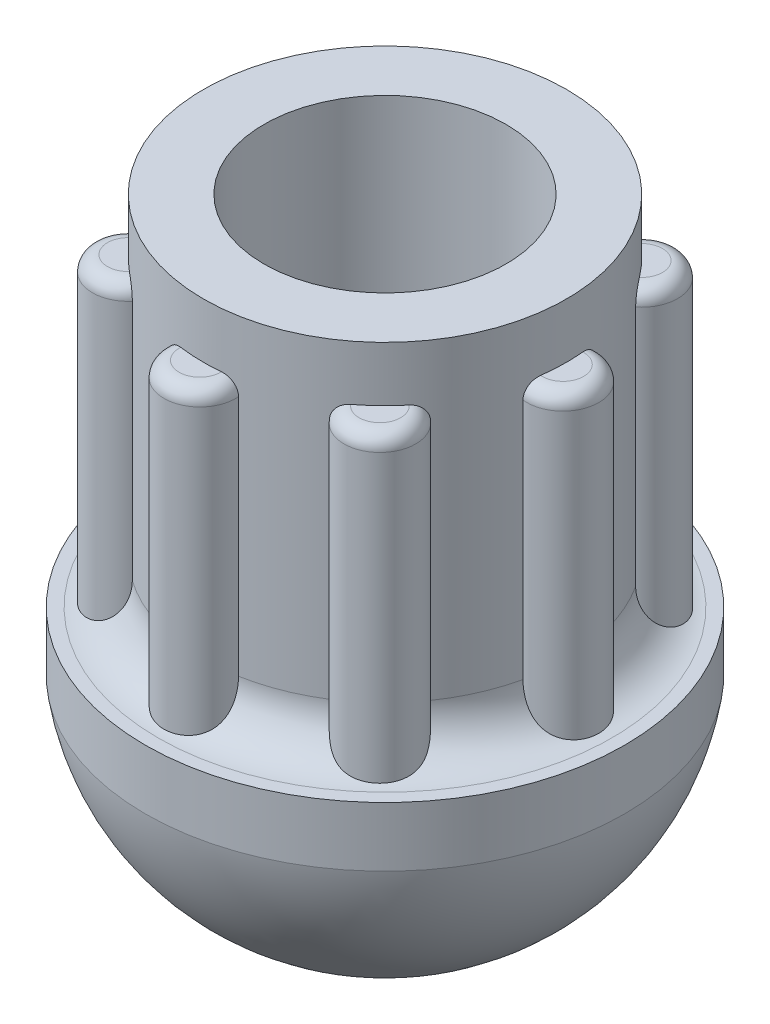
from build123d import *

# Parameters (mm, degrees)
SKETCH2_R           = 1.186722436
BOSS_EXTRUDE1_DEPTH = 10
FILLET1_R           = 0.5


with BuildPart() as part:
    # Sketch1 → Revolve1 (revolve)
    with BuildSketch(Plane.XY):
        with BuildLine():
            Line((0, 0), (0, 8.82467879))
            Line((0, 8.82467879), (2.5, 8.82467879))
            ThreePointArc((2.5, 8.82467879), (3.560660172, 9.264018618), (4, 10.32467879))
            Line((4, 10.32467879), (4, 20.6375))
            Line((4, 20.6375), (6, 20.6375))
            Line((6, 20.6375), (6, 10.32467879))
            ThreePointArc((6, 10.32467879), (6.439339828, 9.264018618), (7.5, 8.82467879))
            Line((7.5, 8.82467879), (7.918196819, 8.82467879))
            Line((7.918196819, 8.82467879), (7.918196819, 6.858878126))
            ThreePointArc((7.918196819, 6.858878126), (5.237891991, 1.953142345), (0, 0))
        make_face()
    revolve(axis=Axis((0, 0, 0), (0, 1, 0)))

    # Sketch2 → Boss-Extrude1 (add)
    with BuildSketch(Plane(origin=(0, 8.82467879, 0), x_dir=(1, 0, 0), z_dir=(0, 1, 0))):
        with Locations((0.118945018, 5.998820891)):
            Circle(SKETCH2_R)
        with Locations((4.32591376, 4.157700103)):
            Circle(SKETCH2_R)
        with Locations((5.998820891, -0.118945018)):
            Circle(SKETCH2_R)
        with Locations((4.157700103, -4.32591376)):
            Circle(SKETCH2_R)
        with Locations((-0.118945018, -5.998820891)):
            Circle(SKETCH2_R)
        with Locations((-4.32591376, -4.157700103)):
            Circle(SKETCH2_R)
        with Locations((-5.998820891, 0.118945018)):
            Circle(SKETCH2_R)
        with Locations((-4.157700103, 4.32591376)):
            Circle(SKETCH2_R)
    extrude(amount=BOSS_EXTRUDE1_DEPTH)

    # Fillet1
    fillet1_edges = [part.edges().sort_by_distance(p)[0] for p in [
        (0.142470804, 18.82467879, -7.185310114),
        (5.181523579, 18.82467879, -4.980039435),
        (7.185310114, 18.82467879, 0.142470804),
        (4.980039435, 18.82467879, 5.181523579),
        (-0.142470804, 18.82467879, 7.185310114),
        (-5.181523579, 18.82467879, 4.980039435),
        (-7.185310114, 18.82467879, -0.142470804),
        (-4.980039435, 18.82467879, -5.181523579),
    ]]
    fillet(fillet1_edges, radius=FILLET1_R)


solid = part.part
